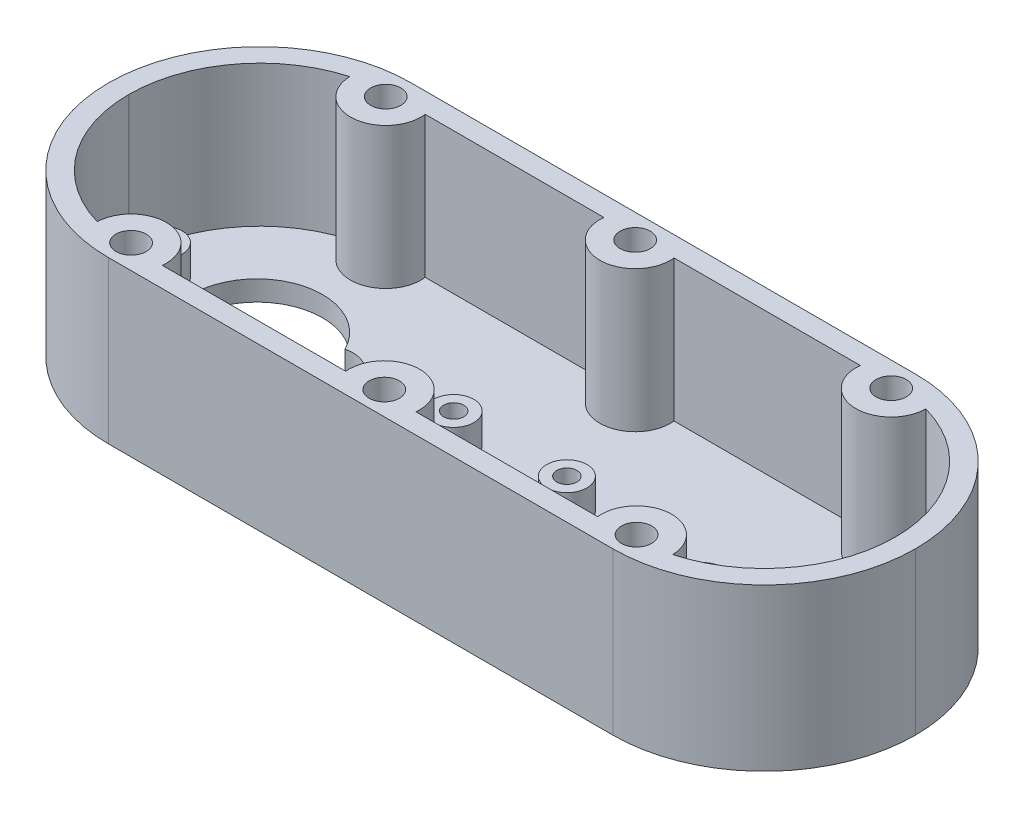
from build123d import *

# Parameters (mm, degrees)
SKETCH3_R            = 1.5
BOSS_EXTRUDE9_DEPTH  = 16
SHELL6_T             = -2
CUT_EXTRUDE3_DEPTH   = 16
SKETCH12_R           = 2
SKETCH12_R_2         = 1
BOSS_EXTRUDE16_DEPTH = 3


with BuildPart() as part:
    # Sketch3 → Boss-Extrude9 (new body)
    with BuildSketch(Plane(origin=(0, 0, 0), x_dir=(1, 0, 0), z_dir=(0, 1, 0))):
        with BuildLine():
            Line((-7.591309311, 15.762711864), (42.428690689, 15.762711864))
            ThreePointArc((42.428690689, 15.762711864), (53.028221339, 11.372242514), (57.418690689, 0.772711864))
            Line((57.418690689, 0.772711864), (57.418690689, 0.752711864))
            ThreePointArc((57.418690689, 0.752711864), (53.028221339, -9.846818786), (42.428690689, -14.237288136))
            Line((42.428690689, -14.237288136), (-7.591309311, -14.237288136))
            ThreePointArc((-7.591309311, -14.237288136), (-18.190839961, -9.846818786), (-22.581309311, 0.752711864))
            Line((-22.581309311, 0.752711864), (-22.581309311, 0.772711864))
            ThreePointArc((-22.581309311, 0.772711864), (-18.190839961, 11.372242514), (-7.591309311, 15.762711864))
        make_face()
        with Locations(Location((-7.655094993, 13.320472835, 0), (0, 0, 270))):
            Circle(SKETCH3_R, mode=Mode.SUBTRACT)
        with Locations(Location((-7.728737311, -11.852412523, 0), (0, 0, 270))):
            Circle(SKETCH3_R, mode=Mode.SUBTRACT)
        with Locations(Location((17.418690689, -11.898221857, 0), (0, 0, 270))):
            Circle(SKETCH3_R, mode=Mode.SUBTRACT)
        with Locations(Location((17.006406688, 13.388530255, 0), (0, 0, 270))):
            Circle(SKETCH3_R, mode=Mode.SUBTRACT)
        with Locations(Location((42.428690689, 13.342720921, 0), (0, 0, 270))):
            Circle(SKETCH3_R, mode=Mode.SUBTRACT)
        with Locations(Location((42.382881356, -11.852412523, 0), (0, 0, 270))):
            Circle(SKETCH3_R, mode=Mode.SUBTRACT)
    extrude(amount=BOSS_EXTRUDE9_DEPTH)

    # Shell6
    shell6_openings = [part.faces().sort_by_distance(p)[0] for p in [
        (17.420843578, 16, -0.763128508),
    ]]
    offset(amount=SHELL6_T, openings=shell6_openings)

    # Sketch6 → Cut-Extrude3 (cut)
    with BuildSketch(Plane(origin=(0, 2, 0), x_dir=(1, 0, 0), z_dir=(0, 1, 0))):
        with BuildLine():
            ThreePointArc((36.601110118, 3.632363117), (48.908802425, 0.713337584), (36.601110118, -2.205687948))
            ThreePointArc((36.601110118, -2.205687948), (32.908802425, 0.713337584), (36.601110118, 3.632363117))
        make_face()
        with BuildLine():
            ThreePointArc((-1.996728909, 3.621416563), (-14.304421217, 0.70239103), (-1.996728909, -2.216634502))
            ThreePointArc((-1.996728909, -2.216634502), (1.695578783, 0.70239103), (-1.996728909, 3.621416563))
        make_face()
    extrude(amount=-CUT_EXTRUDE3_DEPTH, mode=Mode.SUBTRACT)

    # Sketch12 → Boss-Extrude16 (add)
    with BuildSketch(Plane(origin=(0, 2, 0), x_dir=(1, 0, 0), z_dir=(0, 1, 0))):
        with Locations(Location((51.950259108, 0.701799296, 0), (0, 0, 270))):
            Circle(SKETCH12_R)
        with Locations(Location((51.950259108, 0.701799296, 0), (0, 0, 270))):
            Circle(SKETCH12_R_2, mode=Mode.SUBTRACT)
        with Locations(Location((-17.227337288, 0.701799296, 0), (0, 0, 270))):
            Circle(SKETCH12_R)
        with Locations(Location((-17.227337288, 0.701799296, 0), (0, 0, 270))):
            Circle(SKETCH12_R_2, mode=Mode.SUBTRACT)
        with Locations(Location((11.695578783, 0.70239103, 0), (0, 0, 270))):
            Circle(SKETCH12_R)
        with Locations(Location((11.695578783, 0.70239103, 0), (0, 0, 270))):
            Circle(SKETCH12_R_2, mode=Mode.SUBTRACT)
        with Locations(Location((22.908802425, 0.713337584, 0), (0, 0, 270))):
            Circle(SKETCH12_R)
        with Locations(Location((22.908802425, 0.713337584, 0), (0, 0, 270))):
            Circle(SKETCH12_R_2, mode=Mode.SUBTRACT)
    extrude(amount=BOSS_EXTRUDE16_DEPTH)


solid = part.part
